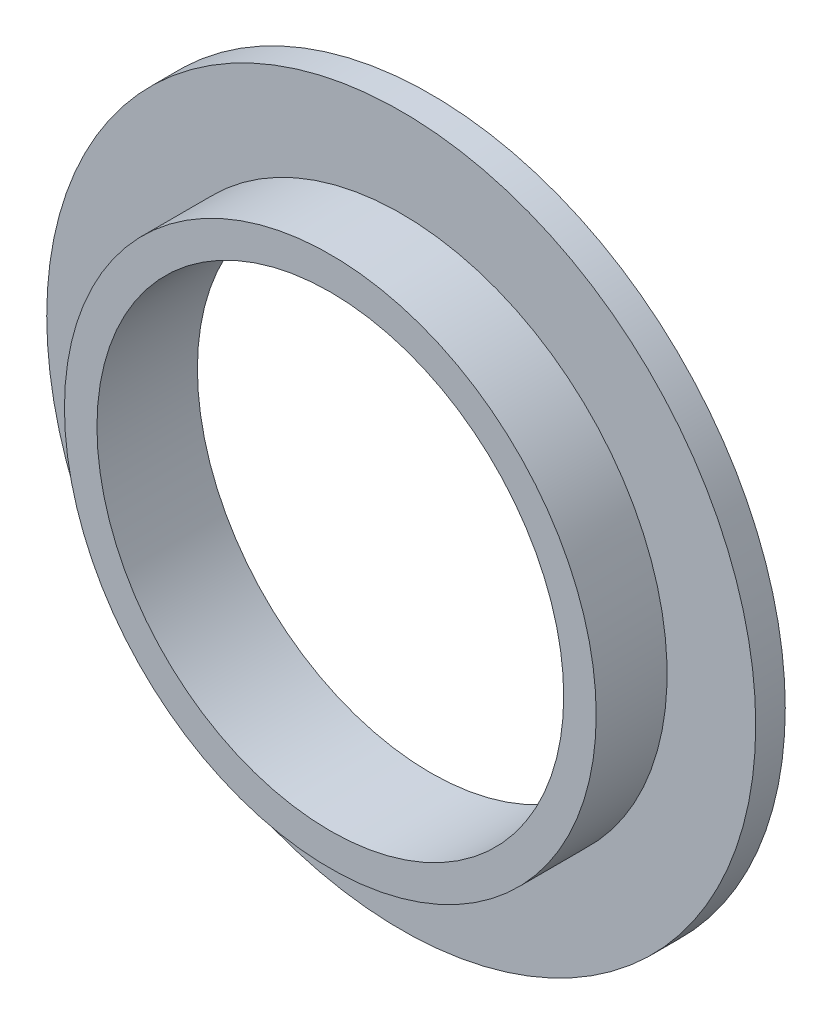
from build123d import *

# Parameters (mm, degrees)
SKETCH1_R           = 28.575
SKETCH1_R_2         = 25.0825
BOSS_EXTRUDE1_DEPTH = 10.795
SKETCH2_R           = 38.1
SKETCH2_R_2         = 28.575
BOSS_EXTRUDE2_DEPTH = 3.175


with BuildPart() as part:
    # Sketch1 → Boss-Extrude1 (new body)
    with BuildSketch(Plane.XY):
        Circle(SKETCH1_R)
        Circle(SKETCH1_R_2, mode=Mode.SUBTRACT)
    extrude(amount=BOSS_EXTRUDE1_DEPTH)

    # Sketch2 → Boss-Extrude2 (add)
    with BuildSketch(Plane(origin=(0, 0, 0), x_dir=(-1, 0, 0), z_dir=(0, 0, -1))):
        Circle(SKETCH2_R)
        Circle(SKETCH2_R_2, mode=Mode.SUBTRACT)
    extrude(amount=-BOSS_EXTRUDE2_DEPTH)


solid = part.part
